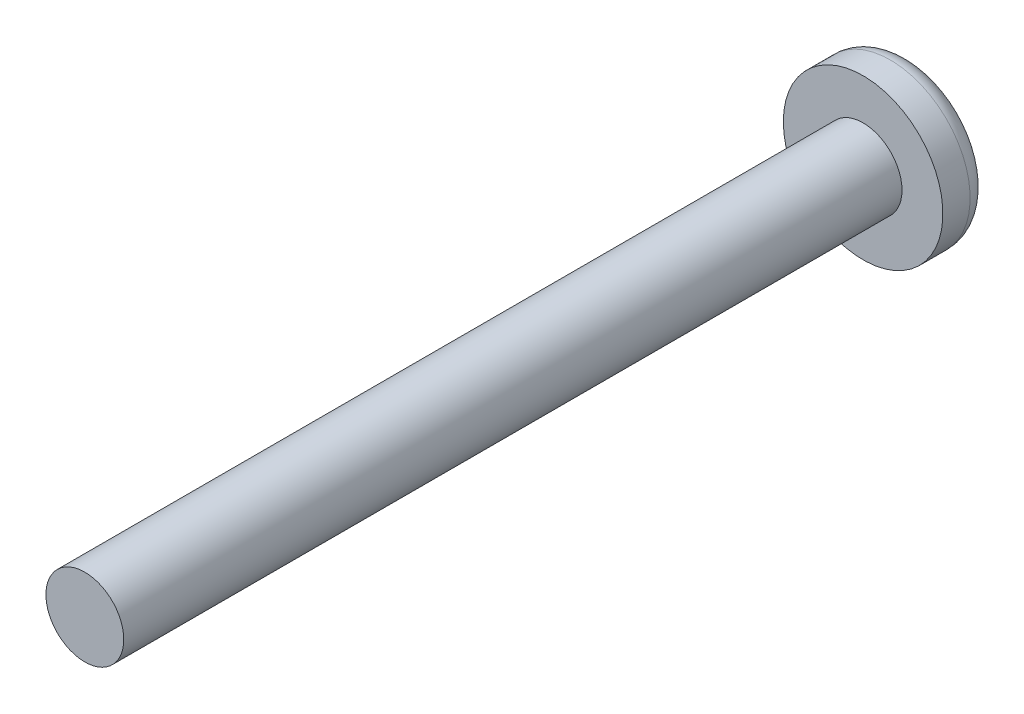
from build123d import *

# Parameters (mm, degrees)
SCHIZZO1_R                   = 1
ESTRUSIONE_ESTRUSIONE1_DEPTH = 20
SCHIZZO2_R                   = 2.05
ESTRUSIONE_ESTRUSIONE2_DEPTH = 1.2
RACCORDO1_R                  = 0.5
TAGLIO_ESTRUSIONE1_DEPTH     = 0.5


with BuildPart() as part:
    # Schizzo1 → Estrusione-Estrusione1 (new body)
    with BuildSketch(Plane.XY):
        Circle(SCHIZZO1_R)
    extrude(amount=ESTRUSIONE_ESTRUSIONE1_DEPTH)

    # Schizzo2 → Estrusione-Estrusione2 (add)
    with BuildSketch(Plane(origin=(0, 0, 0), x_dir=(-1, 0, 0), z_dir=(0, 0, -1))):
        Circle(SCHIZZO2_R)
    extrude(amount=ESTRUSIONE_ESTRUSIONE2_DEPTH)

    # Raccordo1
    raccordo1_edges = [part.edges().sort_by_distance(p)[0] for p in [
        (2.05, 0, -1.2),
    ]]
    fillet(raccordo1_edges, radius=RACCORDO1_R)

    # Schizzo3 → Taglio-Estrusione1 (cut)
    with BuildSketch(Plane(origin=(0, 0, -1.2), x_dir=(-1, 0, 0), z_dir=(0, 0, -1))):
        Polygon((-0.25, 0.25), (-1, 0.25), (-1, -0.25), (-0.25, -0.25), (-0.25, -1), (0.25, -1), (0.25, -0.25), (1, -0.25), (1, 0.25), (0.25, 0.25), (0.25, 1), (-0.25, 1), align=None)
    extrude(amount=-TAGLIO_ESTRUSIONE1_DEPTH, mode=Mode.SUBTRACT)


solid = part.part
